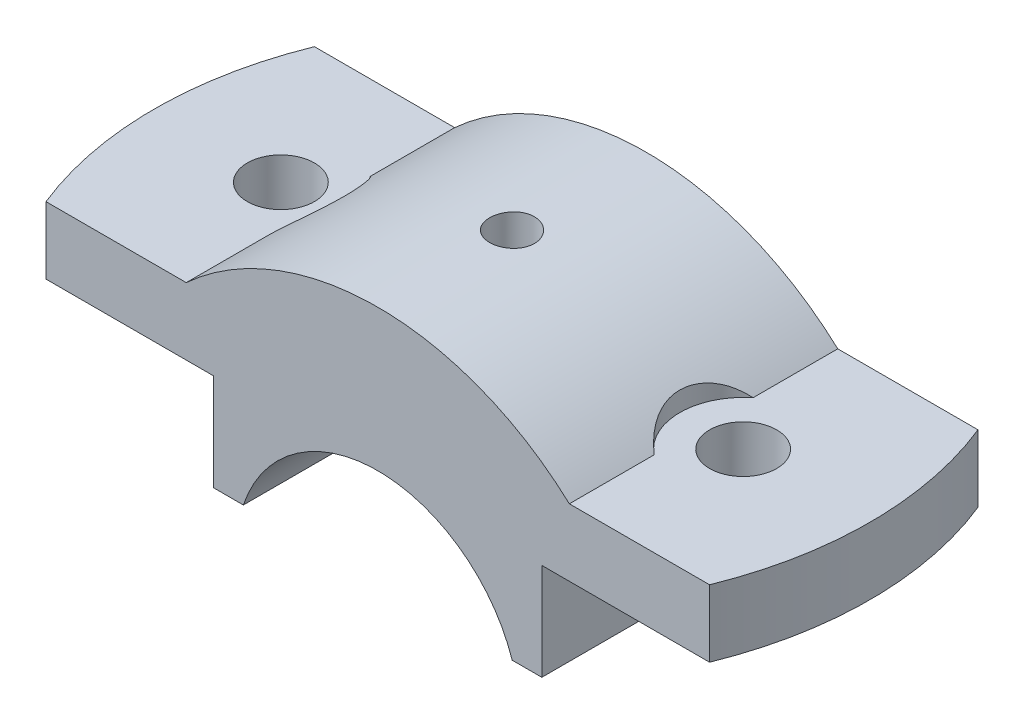
from build123d import *

# Parameters (mm, degrees)
BOSS_EXTRUDE1_DEPTH                     = 18
CUT_EXTRUDE1_DEPTH                      = 23
SKETCH5_R                               = 4.5
CUT_EXTRUDE2_DEPTH                      = 23
SKETCH7_R                               = 8.5
CUT_EXTRUDE4_DEPTH                      = 13
CBORE_FOR_M5_HEX_HEAD_BOLT1_D           = 5
CBORE_FOR_M5_HEX_HEAD_BOLT1_CBORE_D     = 6
CBORE_FOR_M5_HEX_HEAD_BOLT1_CBORE_DEPTH = 13


with BuildPart() as part:
    # Sketch1 → Boss-Extrude1 (new body, symmetric)
    with BuildSketch(Plane.XY):
        with BuildLine():
            Line((22, 6), (22, 19))
            Line((22, 19), (50, 19))
            Line((50, 19), (50, 28))
            Line((50, 28), (25.690465157, 28))
            ThreePointArc((25.690465157, 28), (0, 38), (-25.690465157, 28))
            Line((-25.690465157, 28), (-50, 28))
            Line((-50, 28), (-50, 19))
            Line((-50, 19), (-22, 19))
            Line((-22, 19), (-22, 6))
            Line((-22, 6), (-18.027756377, 6))
            ThreePointArc((-18.027756377, 6), (0, 19), (18.027756377, 6))
            Line((18.027756377, 6), (22, 6))
        make_face()
    extrude(amount=BOSS_EXTRUDE1_DEPTH, both=True)

    # Sketch4 → Cut-Extrude1 (cut, through all)
    with BuildSketch(Plane(origin=(0, 28, 0), x_dir=(1, 0, 0), z_dir=(0, 1, 0))):
        with BuildLine():
            Line((-44.497190923, 18), (-50, 18))
            Line((-50, 18), (-50, -18))
            Line((-50, -18), (-44.497190923, -18))
            ThreePointArc((-44.497190923, -18), (-48, 0), (-44.497190923, 18))
        make_face()
        with BuildLine():
            Line((50, -18), (44.497190923, -18))
            ThreePointArc((44.497190923, -18), (48, 0), (44.497190923, 18))
            Line((44.497190923, 18), (50, 18))
            Line((50, 18), (50, -18))
        make_face()
    extrude(amount=-CUT_EXTRUDE1_DEPTH, mode=Mode.SUBTRACT)

    # Sketch5 → Cut-Extrude2 (cut, through all)
    with BuildSketch(Plane(origin=(0, 28, 0), x_dir=(1, 0, 0), z_dir=(0, 1, 0))):
        with Locations(Location((-31, 0, 0), (0, 0, 180))):  # turned: the seam where the file's is
            Circle(SKETCH5_R)
    cut_extrude2 = extrude(amount=-CUT_EXTRUDE2_DEPTH, mode=Mode.SUBTRACT)

    # Mirror1: Cut-Extrude2 across plane
    add(cut_extrude2.mirror(Plane(origin=(0, 0, 0), x_dir=(0, 0, 1), z_dir=(1, 0, 0))), mode=Mode.SUBTRACT)

    # Sketch7 → Cut-Extrude4 (cut)
    with BuildSketch(Plane(origin=(0, 28, 0), x_dir=(1, 0, 0), z_dir=(0, 1, 0))):
        with Locations((-31, 0)):
            Circle(SKETCH7_R)
    cut_extrude4 = extrude(amount=CUT_EXTRUDE4_DEPTH, mode=Mode.SUBTRACT)

    # CBORE for M5 Hex Head Bolt1 (through all)
    with Locations(Plane(origin=(0, 38, 0), x_dir=(1, 0, 0), z_dir=(0, 1, 0))):
        with Locations((0, 0)):
            CounterBoreHole(CBORE_FOR_M5_HEX_HEAD_BOLT1_D / 2, CBORE_FOR_M5_HEX_HEAD_BOLT1_CBORE_D / 2, CBORE_FOR_M5_HEX_HEAD_BOLT1_CBORE_DEPTH)

    # Mirror2: Cut-Extrude4 across plane
    add(cut_extrude4.mirror(Plane(origin=(0, 0, 0), x_dir=(0, 0, 1), z_dir=(1, 0, 0))), mode=Mode.SUBTRACT)


solid = part.part
